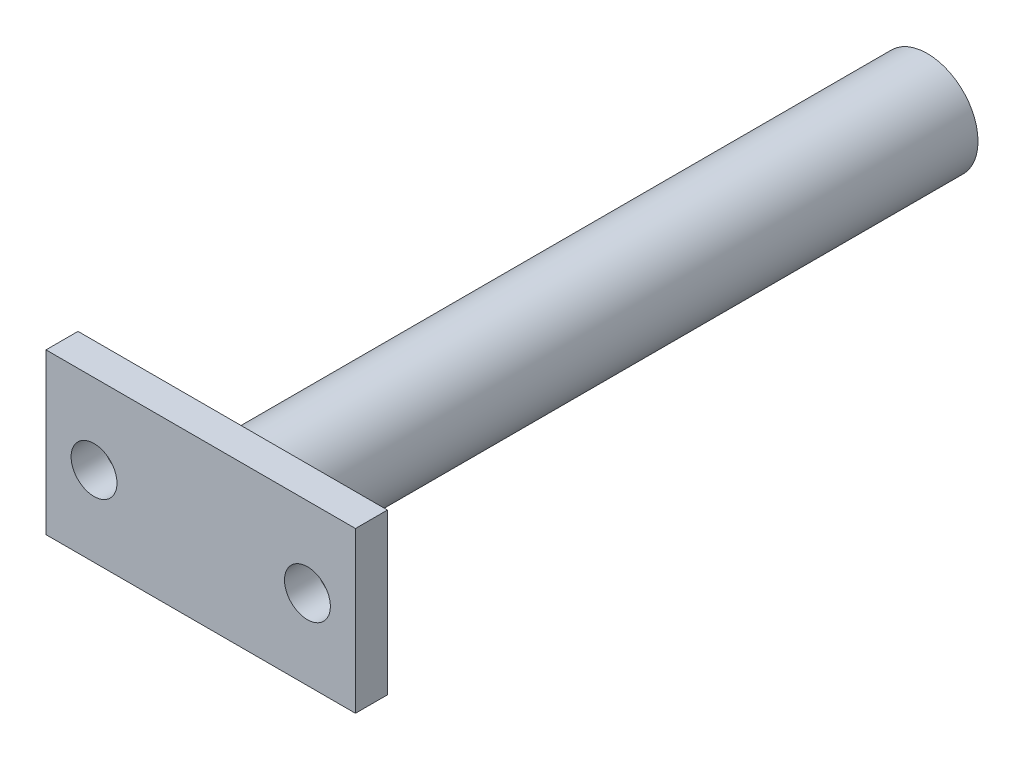
from build123d import *

# Parameters (mm, degrees)
SKETCH1_W                = 29
SKETCH1_H                = 15
SKETCH1_R                = 2.15
SKETCH1_R_2              = 4.75
BOSS_EXTRUDE1_DEPTH      = 3
SKETCH1_3_R              = 4.75
BOSS_EXTRUDE2_DEPTH      = 3
BOSS_EXTRUDE2_DEPTH_BACK = 65.1


with BuildPart() as part:
    # Sketch1 → Boss-Extrude1 (new body)
    with BuildSketch(Plane.XY):
        with Locations((-13.13286664, 8.093964388)):
            Rectangle(SKETCH1_W, SKETCH1_H)
        with Locations((-23.13286664, 8.093964388)):
            Circle(SKETCH1_R, mode=Mode.SUBTRACT)
        with Locations((-13.140365172, 8.093964388)):
            Circle(SKETCH1_R_2, mode=Mode.SUBTRACT)
        with Locations((-3.13286664, 8.093964388)):
            Circle(SKETCH1_R, mode=Mode.SUBTRACT)
    extrude(amount=BOSS_EXTRUDE1_DEPTH)

    # Sketch1_3 → Boss-Extrude2 (add, two sides)
    with BuildSketch(Plane.XY) as boss_extrude2_sk:
        with Locations((-13.140365172, 8.093964388)):
            Circle(SKETCH1_3_R)
    extrude(amount=BOSS_EXTRUDE2_DEPTH)
    extrude(boss_extrude2_sk.sketch, amount=-BOSS_EXTRUDE2_DEPTH_BACK)


solid = part.part
